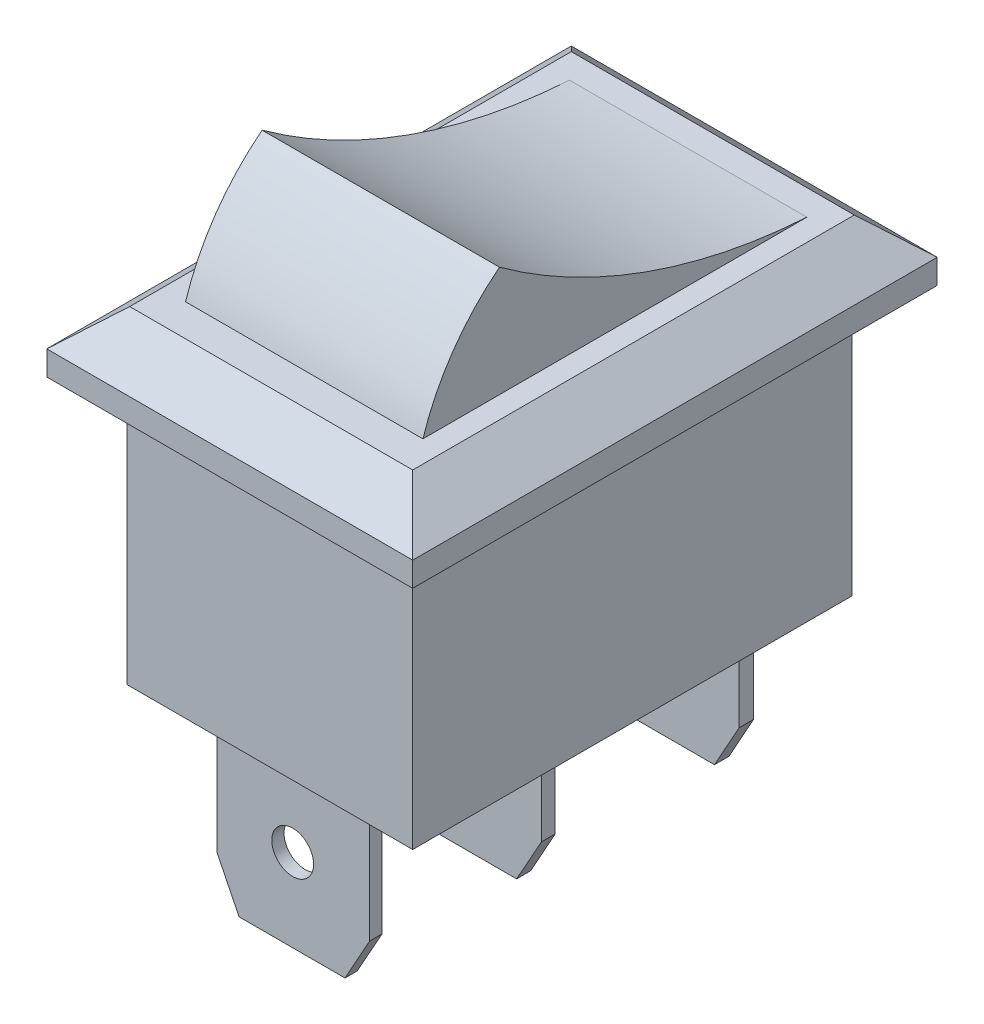
from build123d import *

# Parameters (mm, degrees)
SKETCH1_W             = 15
SKETCH1_H             = 21.5
BOSS_EXTRUDE1_DEPTH   = 2.5
CHAMFER1_SIZE         = 1.5
CHAMFER1_SIZE2        = 1.7
CHAMFER1_PART_2_SIZE  = 1.5
CHAMFER1_PART_2_SIZE2 = 1.7
CHAMFER1_PART_3_SIZE  = 1.5
CHAMFER1_PART_3_SIZE2 = 1.7
CHAMFER1_PART_4_SIZE  = 1.5
CHAMFER1_PART_4_SIZE2 = 1.7
SKETCH3_W             = 11.7
SKETCH3_H             = 18
BOSS_EXTRUDE2_DEPTH   = 11
SKETCH4_W             = 6.25827791
SKETCH4_H             = 0.502489468
SKETCH4_H_2           = 0.571010759
SKETCH4_H_3           = 0.593851189
BOSS_EXTRUDE3_DEPTH   = 7
SKETCH5_R             = 0.857772401
CUT_EXTRUDE1_DEPTH    = 22
BOSS_EXTRUDE4_DEPTH   = 22
SKETCH8_W             = 6.303958771
SKETCH8_H             = 16.703004391
SKETCH8_W_2           = 12.882002706
SKETCH8_H_2           = 17.251174719
CUT_EXTRUDE2_DEPTH    = 16


with BuildPart() as part:
    # Sketch1 → Boss-Extrude1 (new body)
    with BuildSketch(Plane(origin=(0, 0, 0), x_dir=(1, 0, 0), z_dir=(0, 1, 0))):
        with Locations((1.401590457, -5.203280318)):
            Rectangle(SKETCH1_W, SKETCH1_H)
    extrude(amount=BOSS_EXTRUDE1_DEPTH)

    # Chamfer1
    chamfer1_edges = [part.edges().sort_by_distance(p)[0] for p in [
        (8.901590457, 2.5, 5.203280318),
    ]]
    chamfer1_side = [part.faces().sort_by_distance(p)[0] for p in [
        (8.901590457, 1.25, 5.203280318),
    ]]
    chamfer(chamfer1_edges, length=CHAMFER1_SIZE, length2=CHAMFER1_SIZE2, reference=chamfer1_side[0])

    # Chamfer1 part 2
    chamfer1_part_2_edges = [part.edges().sort_by_distance(p)[0] for p in [
        (1.401590457, 2.5, -5.546719682),
    ]]
    chamfer1_part_2_side = [part.faces().sort_by_distance(p)[0] for p in [
        (1.401590457, 1.25, -5.546719682),
    ]]
    chamfer(chamfer1_part_2_edges, length=CHAMFER1_PART_2_SIZE, length2=CHAMFER1_PART_2_SIZE2, reference=chamfer1_part_2_side[0])

    # Chamfer1 part 3
    chamfer1_part_3_edges = [part.edges().sort_by_distance(p)[0] for p in [
        (-6.098409543, 2.5, 5.203280318),
    ]]
    chamfer1_part_3_side = [part.faces().sort_by_distance(p)[0] for p in [
        (-6.098409543, 1.25, 5.203280318),
    ]]
    chamfer(chamfer1_part_3_edges, length=CHAMFER1_PART_3_SIZE, length2=CHAMFER1_PART_3_SIZE2, reference=chamfer1_part_3_side[0])

    # Chamfer1 part 4
    chamfer1_part_4_edges = [part.edges().sort_by_distance(p)[0] for p in [
        (1.401590457, 2.5, 15.953280318),
    ]]
    chamfer1_part_4_side = [part.faces().sort_by_distance(p)[0] for p in [
        (1.401590457, 1.25, 15.953280318),
    ]]
    chamfer(chamfer1_part_4_edges, length=CHAMFER1_PART_4_SIZE, length2=CHAMFER1_PART_4_SIZE2, reference=chamfer1_part_4_side[0])

    # Sketch3 → Boss-Extrude2 (add)
    with BuildSketch(Plane.XZ):
        with Locations((1.324498787, 5.226991199)):
            Rectangle(SKETCH3_W, SKETCH3_H)
    extrude(amount=BOSS_EXTRUDE2_DEPTH)

    # Sketch4 → Boss-Extrude3 (add)
    with BuildSketch(Plane.XZ.offset(11)):
        with Locations((1.23028723, 12.923345769)):
            Rectangle(SKETCH4_W, SKETCH4_H)
        with Locations((1.23028723, 5.854232582)):
            Rectangle(SKETCH4_W, SKETCH4_H_2)
        with Locations((1.23028723, -2.265540399)):
            Rectangle(SKETCH4_W, SKETCH4_H_3)
    extrude(amount=BOSS_EXTRUDE3_DEPTH)

    # Sketch5 → Cut-Extrude1 (cut)
    with BuildSketch(Plane(origin=(0, 0, -2.562465994), x_dir=(-1, 0, 0), z_dir=(0, 0, -1))):
        with Locations((-1.203624554, -14.610197603)):
            Circle(SKETCH5_R)
        Polygon((-3.009226286, -18.607426263), (-4.889542572, -15.232818889), (-5.175948364, -18.482902006), align=None)
        Polygon((0.726501434, -18.545164135), (2.357769206, -15.232818889), (2.818508958, -18.545164135), align=None)
    extrude(amount=-CUT_EXTRUDE1_DEPTH, mode=Mode.SUBTRACT)

    # Sketch7 → Boss-Extrude4 (add)
    with BuildSketch(Plane.ZY.offset(6.098409543)):
        with BuildLine():
            Line((12.938985356, 2.5), (-2.797520118, 2.5))
            ThreePointArc((-2.797520118, 2.5), (3.824713578, 3.86461935), (9.802054281, 7.02492997))
            ThreePointArc((9.802054281, 7.02492997), (11.710383364, 4.998077143), (12.938985356, 2.5))
        make_face()
    extrude(amount=-BOSS_EXTRUDE4_DEPTH)

    # Sketch8 → Cut-Extrude2 (cut)
    with BuildSketch(Plane(origin=(0, 2.5, 0), x_dir=(1, 0, 0), z_dir=(0, 1, 0))):
        with Locations((-6.575725783, -5.553982078)):
            Rectangle(SKETCH8_W, SKETCH8_H)
        with Locations((12.747278275, -5.828067242)):
            Rectangle(SKETCH8_W_2, SKETCH8_H_2)
    extrude(amount=CUT_EXTRUDE2_DEPTH, mode=Mode.SUBTRACT)


solid = part.part
